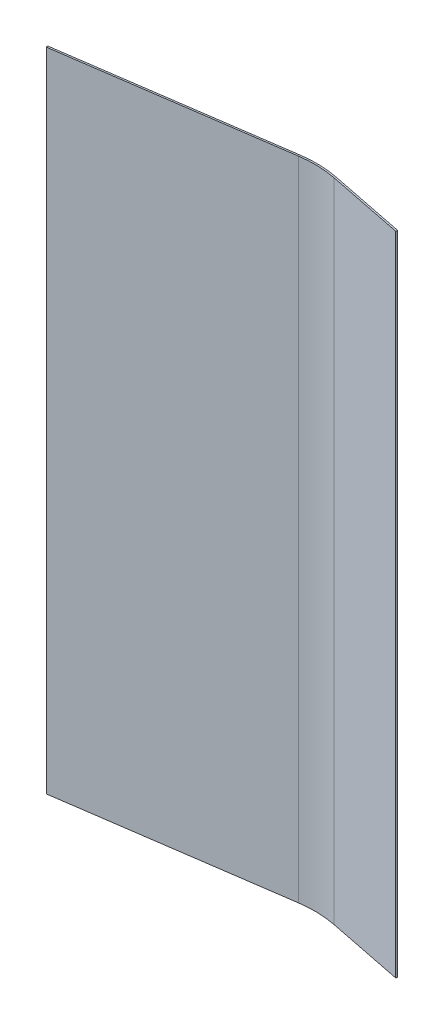
from build123d import *

# Parameters (mm, degrees)
FORCAD_DEPTH = 609.6
FILLET1_R    = 101.6


with BuildPart() as part:
    # Sketch1 → ForCAD (new body)
    with BuildSketch(Plane(origin=(0, 0, 0), x_dir=(1, 0, 0), z_dir=(0, 1, 0))):
        Polygon((0, 0), (225.091665708, 32.392093885), (314.955840223, 14.435459902), (315.266904727, 15.992185673), (225.135389647, 34.002239572), (-0.226121766, 1.571313208), align=None)
    extrude(amount=FORCAD_DEPTH)

    # Fillet1
    fillet1_edges = [part.edges().sort_by_distance(p)[0] for p in [
        (225.135389647, 304.8, -34.002239572),
        (225.091665708, 304.8, -32.392093885),
    ]]
    fillet(fillet1_edges, radius=FILLET1_R)


solid = part.part
